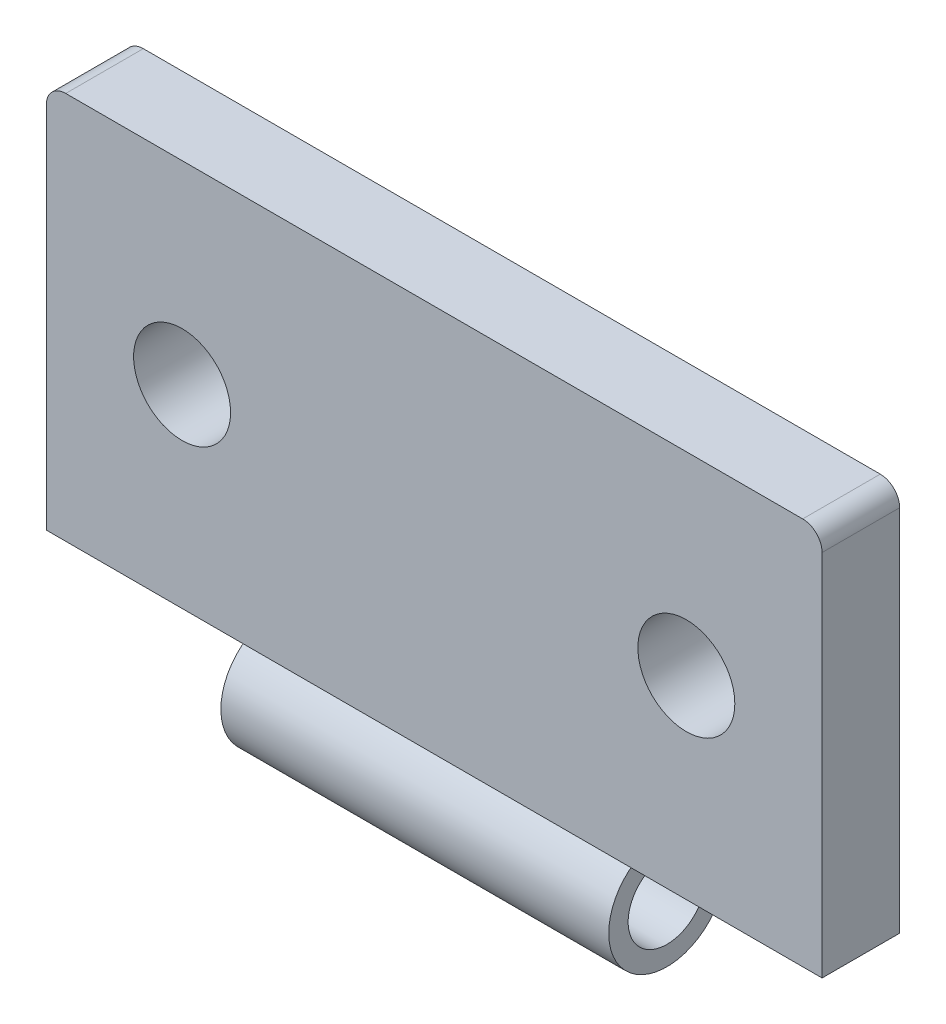
from build123d import *

# Parameters (mm, degrees)
SKETCH2_W           = 40
SKETCH2_H           = 20
SKETCH2_R           = 2.5
BOSS_EXTRUDE2_DEPTH = 2
SKETCH5_R           = 3
SKETCH5_R_2         = 2
BOSS_EXTRUDE3_DEPTH = 10
FILLET1_R           = 1


with BuildPart() as part:
    # Sketch2 → Boss-Extrude2 (new body, symmetric)
    with BuildSketch(Plane.XY):
        Rectangle(SKETCH2_W, SKETCH2_H)
        with Locations((-13, 0)):
            Circle(SKETCH2_R, mode=Mode.SUBTRACT)
        with Locations((13, 0)):
            Circle(SKETCH2_R, mode=Mode.SUBTRACT)
    extrude(amount=BOSS_EXTRUDE2_DEPTH, both=True)

    # Sketch5 → Boss-Extrude3 (add, symmetric)
    with BuildSketch(Plane(origin=(0, 0, 0), x_dir=(0, 0, -1), z_dir=(1, 0, 0))):
        with Locations((0, -12.5)):
            Circle(SKETCH5_R)
        with Locations((0, -12.5)):
            Circle(SKETCH5_R_2, mode=Mode.SUBTRACT)
    extrude(amount=BOSS_EXTRUDE3_DEPTH, both=True)

    # Fillet1
    fillet1_edges = [part.edges().sort_by_distance(p)[0] for p in [
        (-20, 10, 0),
        (20, 10, 0),
    ]]
    fillet(fillet1_edges, radius=FILLET1_R)


solid = part.part
